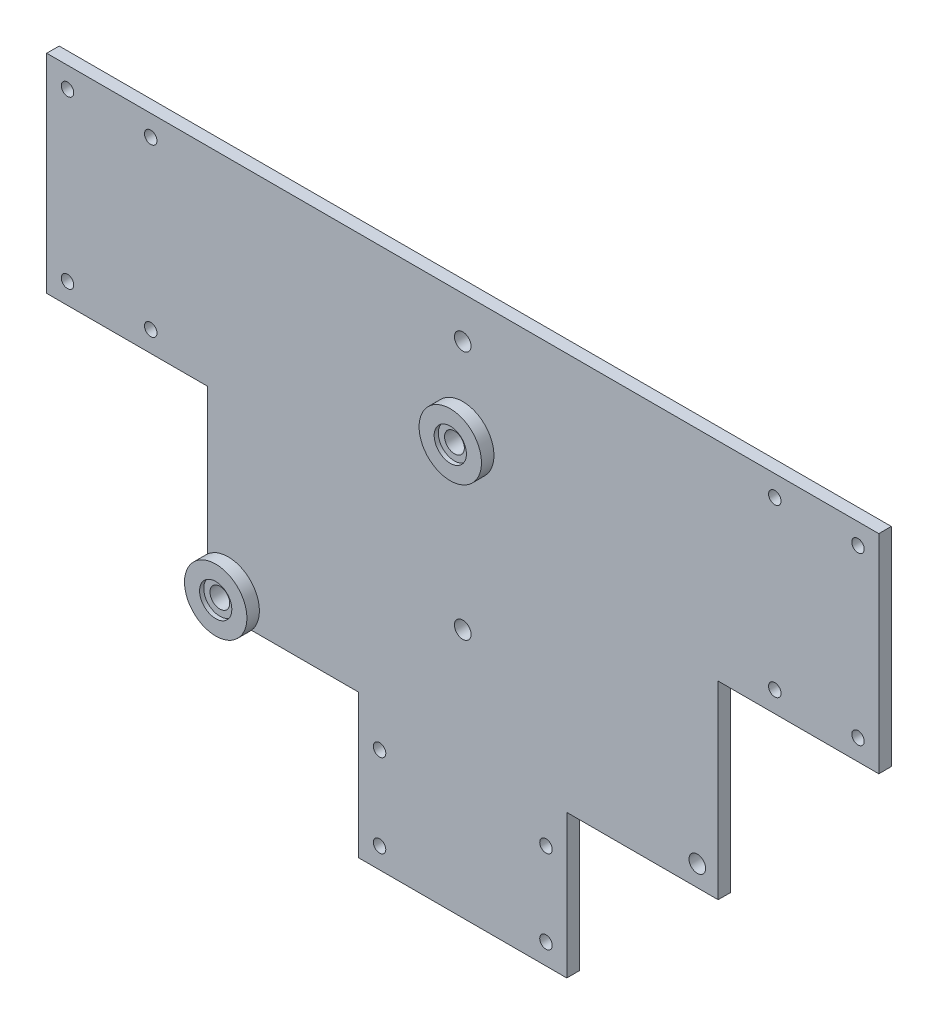
from build123d import *

# Parameters (mm, degrees)
ESQUISSE1_R             = 2
ESQUISSE1_R_2           = 1.5
BOSS_EXTRU_1_DEPTH      = 3
ESQUISSE3_R             = 7.5
BOSS_EXTRU_2_DEPTH      = 6
ESQUISSE4_R             = 3.875
ENL_V_MAT_EXTRU_1_DEPTH = 1
ESQUISSE5_R             = 2.375
ENL_V_MAT_EXTRU_2_DEPTH = 4


with BuildPart() as part:
    # Esquisse1 → Boss.-Extru.1 (new body)
    with BuildSketch(Plane.XY):
        Polygon((0, 50), (-100, 50), (-100, 0), (-61.381557247, 0), (-61.381557247, -45.5212086), (-25, -45.5212086), (-25, -80), (25, -80), (25, -45.5212086), (61.381557247, -45.5212086), (61.381557247, 0), (100, 0), (100, 50), align=None)
        with Locations((0, 20)):
            Circle(ESQUISSE1_R, mode=Mode.SUBTRACT)
        with Locations((0, -20)):
            Circle(ESQUISSE1_R, mode=Mode.SUBTRACT)
        with Locations((0, 40)):
            Circle(ESQUISSE1_R, mode=Mode.SUBTRACT)
        with Locations((-20, -55)):
            Circle(ESQUISSE1_R_2, mode=Mode.SUBTRACT)
        with Locations((20, -55)):
            Circle(ESQUISSE1_R_2, mode=Mode.SUBTRACT)
        with Locations((20, -75)):
            Circle(ESQUISSE1_R_2, mode=Mode.SUBTRACT)
        with Locations((-20, -75)):
            Circle(ESQUISSE1_R_2, mode=Mode.SUBTRACT)
        with Locations((-95, 45)):
            Circle(ESQUISSE1_R_2, mode=Mode.SUBTRACT)
        with Locations((-75, 45)):
            Circle(ESQUISSE1_R_2, mode=Mode.SUBTRACT)
        with Locations((-75, 5)):
            Circle(ESQUISSE1_R_2, mode=Mode.SUBTRACT)
        with Locations((-95, 5)):
            Circle(ESQUISSE1_R_2, mode=Mode.SUBTRACT)
        with Locations((75, 5)):
            Circle(ESQUISSE1_R_2, mode=Mode.SUBTRACT)
        with Locations((95, 5)):
            Circle(ESQUISSE1_R_2, mode=Mode.SUBTRACT)
        with Locations((75, 45)):
            Circle(ESQUISSE1_R_2, mode=Mode.SUBTRACT)
        with Locations((95, 45)):
            Circle(ESQUISSE1_R_2, mode=Mode.SUBTRACT)
        with Locations((56.381557247, -40.5212086)):
            Circle(ESQUISSE1_R, mode=Mode.SUBTRACT)
        with Locations((-56.381557247, -40.5212086)):
            Circle(ESQUISSE1_R, mode=Mode.SUBTRACT)
    extrude(amount=BOSS_EXTRU_1_DEPTH)

    # Esquisse3 → Boss.-Extru.2 (add)
    with BuildSketch(Plane(origin=(0, 0, 0), x_dir=(-1, 0, 0), z_dir=(0, 0, -1))):
        with Locations((0, 20)):
            Circle(ESQUISSE3_R)
        with Locations((56.381557247, -40.5212086)):
            Circle(ESQUISSE3_R)
    extrude(amount=-BOSS_EXTRU_2_DEPTH)

    # Esquisse4 → Enlèv. mat.-Extru.1 (cut)
    with BuildSketch(Plane.XY.offset(6)):
        with Locations((-56.381557247, -40.5212086)):
            Circle(ESQUISSE4_R)
        with Locations((0, 20)):
            Circle(ESQUISSE4_R)
    extrude(amount=-ENL_V_MAT_EXTRU_1_DEPTH, mode=Mode.SUBTRACT)

    # Esquisse5 → Enlèv. mat.-Extru.2 (cut)
    with BuildSketch(Plane.XY.offset(5)):
        with Locations((-56.381557247, -40.5212086)):
            Circle(ESQUISSE5_R)
        with Locations((0, 20)):
            Circle(ESQUISSE5_R)
    extrude(amount=-ENL_V_MAT_EXTRU_2_DEPTH, mode=Mode.SUBTRACT)


solid = part.part
